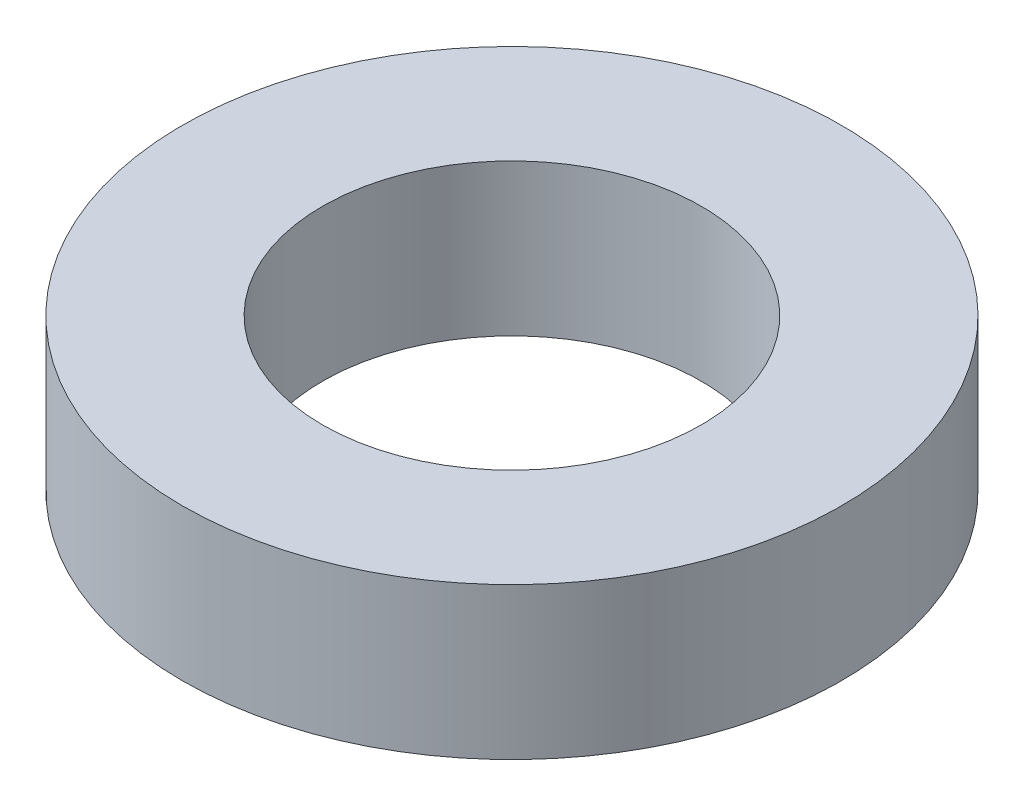
from build123d import *

# Parameters (mm, degrees)
SKETCH1_R           = 11.049
SKETCH1_R_2         = 6.35
BOSS_EXTRUDE1_DEPTH = 5.08


with BuildPart() as part:
    # Sketch1 → Boss-Extrude1 (new body)
    with BuildSketch(Plane(origin=(0, 0, 0), x_dir=(1, 0, 0), z_dir=(0, 1, 0))):
        Circle(SKETCH1_R)
        Circle(SKETCH1_R_2, mode=Mode.SUBTRACT)
    extrude(amount=BOSS_EXTRUDE1_DEPTH)


solid = part.part
